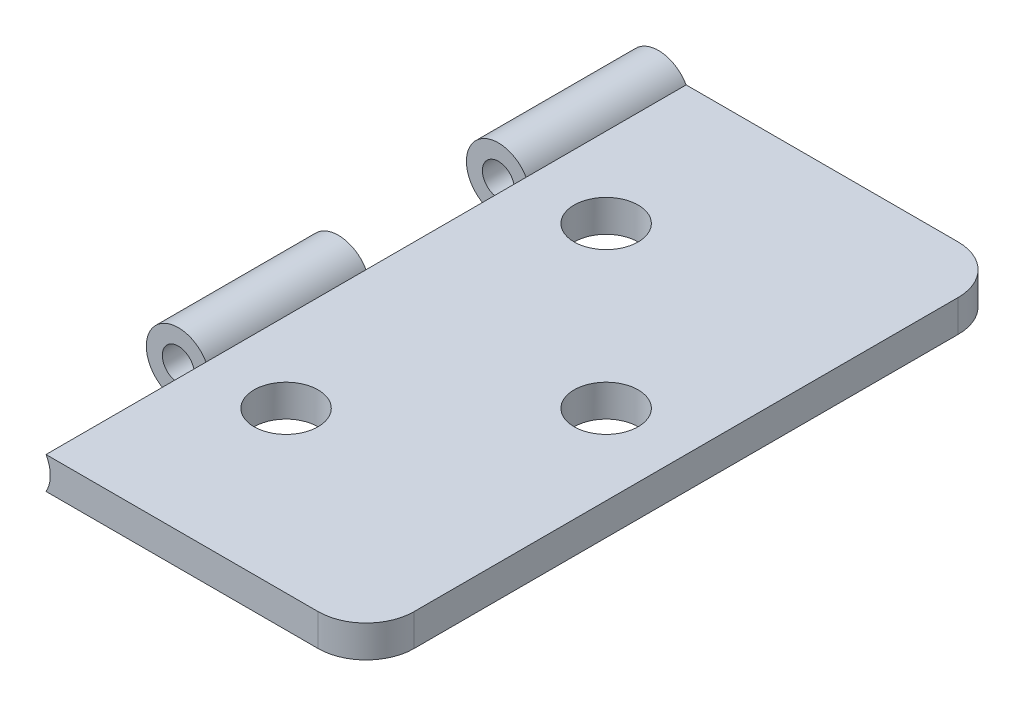
from build123d import *

# Parameters (mm, degrees)
BOSS_EXTRUDE1_DEPTH = 40
BOSS_EXTRUDE2_START = -10
SKETCH1_3_R         = 1
BOSS_EXTRUDE2_DEPTH = 10
BOSS_EXTRUDE3_START = -30
SKETCH1_4_R         = 1
BOSS_EXTRUDE3_DEPTH = 10
SKETCH2_R           = 2
CUT_EXTRUDE1_DEPTH  = 10
FILLET1_R           = 3
FILLET2_R           = 3


with BuildPart() as part:
    # Sketch1 → Boss-Extrude1 (new body)
    with BuildSketch(Plane.XY):
        with BuildLine():
            Line((33.441058941, -2), (33.441058941, 0))
            Line((33.441058941, 0), (13.441058941, 0))
            ThreePointArc((13.441058941, 0), (13.640859786, -0.48236191), (13.709008133, -1))
            ThreePointArc((13.709008133, -1), (13.640859786, -1.51763809), (13.441058941, -2))
            Line((13.441058941, -2), (33.441058941, -2))
        make_face()
    extrude(amount=-BOSS_EXTRUDE1_DEPTH)

    # Sketch1_3 → Boss-Extrude2 (add)
    with BuildSketch(Plane.XY.offset(BOSS_EXTRUDE2_START)):
        with BuildLine():
            ThreePointArc((13.709008133, -1), (13.640859786, -0.48236191), (13.441058941, 0))
            ThreePointArc((13.441058941, 0), (9.709008133, -1), (13.441058941, -2))
            ThreePointArc((13.441058941, -2), (13.640859786, -1.51763809), (13.709008133, -1))
        make_face()
        with Locations((11.709008133, -1)):
            Circle(SKETCH1_3_R, mode=Mode.SUBTRACT)
    extrude(amount=-BOSS_EXTRUDE2_DEPTH)

    # Sketch1_4 → Boss-Extrude3 (add)
    with BuildSketch(Plane.XY.offset(BOSS_EXTRUDE3_START)):
        with BuildLine():
            ThreePointArc((13.709008133, -1), (13.640859786, -0.48236191), (13.441058941, 0))
            ThreePointArc((13.441058941, 0), (9.709008133, -1), (13.441058941, -2))
            ThreePointArc((13.441058941, -2), (13.640859786, -1.51763809), (13.709008133, -1))
        make_face()
        with Locations((11.709008133, -1)):
            Circle(SKETCH1_4_R, mode=Mode.SUBTRACT)
    extrude(amount=-BOSS_EXTRUDE3_DEPTH)

    # Sketch2 → Cut-Extrude1 (cut)
    with BuildSketch(Plane(origin=(0, 0, 0), x_dir=(1, 0, 0), z_dir=(0, 1, 0))):
        with Locations((18.441058941, 30)):
            Circle(SKETCH2_R)
        with Locations((18.441058941, 10)):
            Circle(SKETCH2_R)
        with Locations((28.441058941, 20)):
            Circle(SKETCH2_R)
    extrude(amount=-CUT_EXTRUDE1_DEPTH, mode=Mode.SUBTRACT)

    # Fillet1
    fillet1_edges = [part.edges().sort_by_distance(p)[0] for p in [
        (33.441058941, -1, 0),
    ]]
    fillet(fillet1_edges, radius=FILLET1_R)

    # Fillet2
    fillet2_edges = [part.edges().sort_by_distance(p)[0] for p in [
        (33.441058941, -1, -40),
    ]]
    fillet(fillet2_edges, radius=FILLET2_R)


solid = part.part
